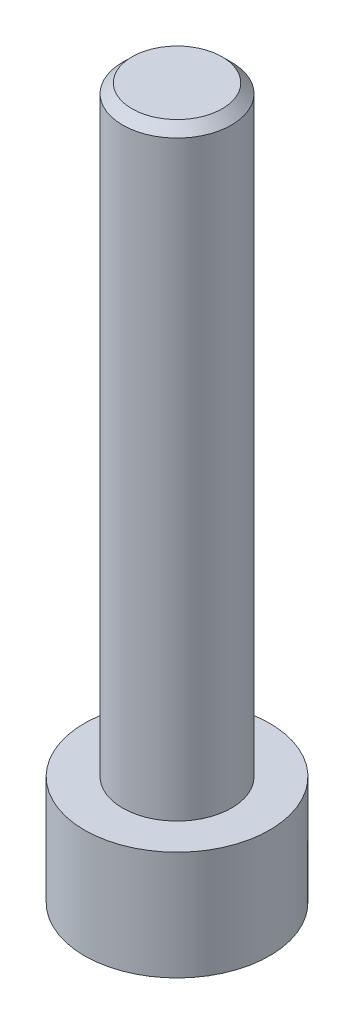
from build123d import *

# Parameters (mm, degrees)
SKETCH1_R           = 2.465
BOSS_EXTRUDE1_DEPTH = 2.9
SKETCH2_R           = 1.45
BOSS_EXTRUDE2_DEPTH = 16
CUT_EXTRUDE1_DEPTH  = 1.9
CHAMFER1_SIZE       = 0.25


with BuildPart() as part:
    # Sketch1 → Boss-Extrude1 (new body)
    with BuildSketch(Plane(origin=(0, 0, 0), x_dir=(1, 0, 0), z_dir=(0, 1, 0))):
        Circle(SKETCH1_R)
    extrude(amount=BOSS_EXTRUDE1_DEPTH)

    # Sketch2 → Boss-Extrude2 (add)
    with BuildSketch(Plane(origin=(0, 2.9, 0), x_dir=(1, 0, 0), z_dir=(0, 1, 0))):
        Circle(SKETCH2_R)
    extrude(amount=BOSS_EXTRUDE2_DEPTH)

    # Sketch3 → Cut-Extrude1 (cut)
    with BuildSketch(Plane.XZ):
        Polygon((0.733234842, -1.27), (1.466469684, 0), (0.733234842, 1.27), (-0.733234842, 1.27), (-1.466469684, 0), (-0.733234842, -1.27), align=None)
    extrude(amount=-CUT_EXTRUDE1_DEPTH, mode=Mode.SUBTRACT)

    # Chamfer1
    chamfer1_edges = [part.edges().sort_by_distance(p)[0] for p in [
        (-1.45, 18.9, 0),
    ]]
    chamfer(chamfer1_edges, length=CHAMFER1_SIZE)


solid = part.part
